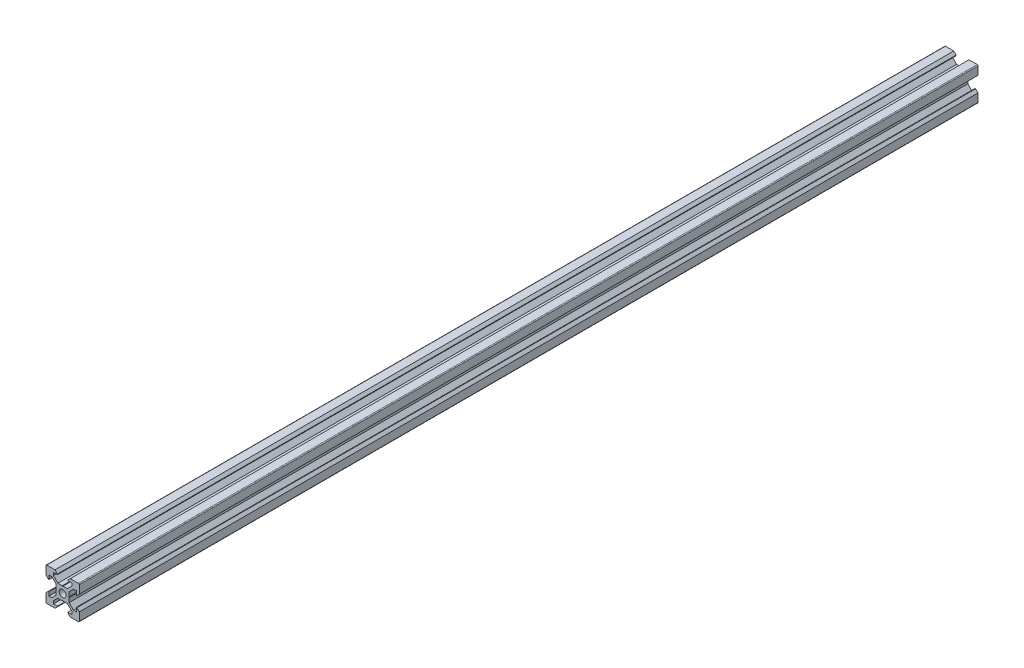
from build123d import *

# Parameters (mm, degrees)
SKETCH1_R           = 2.1
BOSS_EXTRUDE1_DEPTH = 540


with BuildPart() as part:
    # Sketch1 → Boss-Extrude1 (new body)
    with BuildSketch(Plane.XY):
        with BuildLine():
            Line((4.58, -10), (9.5, -10))
            ThreePointArc((9.5, -10), (9.853553391, -9.853553391), (10, -9.5))
            Line((10, -9.5), (10, -4.58))
            Line((10, -4.58), (8.545, -3.125))
            Line((8.545, -3.125), (8.2, -3.125))
            Line((8.2, -3.125), (8.2, -5.5))
            Line((8.2, -5.5), (6.560660172, -5.5))
            Line((6.560660172, -5.5), (3.9, -2.839339828))
            Line((3.9, -2.839339828), (3.9, -0.21))
            Line((3.9, -0.21), (3.69, 0))
            Line((3.69, 0), (3.9, 0.21))
            Line((3.9, 0.21), (3.9, 2.839339828))
            Line((3.9, 2.839339828), (6.560660172, 5.5))
            Line((6.560660172, 5.5), (8.2, 5.5))
            Line((8.2, 5.5), (8.2, 3.125))
            Line((8.2, 3.125), (8.545, 3.125))
            Line((8.545, 3.125), (10, 4.58))
            Line((10, 4.58), (10, 9.5))
            ThreePointArc((10, 9.5), (9.853553391, 9.853553391), (9.5, 10))
            Line((9.5, 10), (4.58, 10))
            Line((4.58, 10), (3.125, 8.545))
            Line((3.125, 8.545), (3.125, 8.2))
            Line((3.125, 8.2), (5.5, 8.2))
            Line((5.5, 8.2), (5.5, 6.560660172))
            Line((5.5, 6.560660172), (2.839339828, 3.9))
            Line((2.839339828, 3.9), (0.21, 3.9))
            Line((0.21, 3.9), (0, 3.69))
            Line((0, 3.69), (-0.21, 3.9))
            Line((-0.21, 3.9), (-2.839339828, 3.9))
            Line((-2.839339828, 3.9), (-5.5, 6.560660172))
            Line((-5.5, 6.560660172), (-5.5, 8.2))
            Line((-5.5, 8.2), (-3.125, 8.2))
            Line((-3.125, 8.2), (-3.125, 8.545))
            Line((-3.125, 8.545), (-4.58, 10))
            Line((-4.58, 10), (-9.5, 10))
            ThreePointArc((-9.5, 10), (-9.853553391, 9.853553391), (-10, 9.5))
            Line((-10, 9.5), (-10, 4.58))
            Line((-10, 4.58), (-8.545, 3.125))
            Line((-8.545, 3.125), (-8.2, 3.125))
            Line((-8.2, 3.125), (-8.2, 5.5))
            Line((-8.2, 5.5), (-6.560660172, 5.5))
            Line((-6.560660172, 5.5), (-3.9, 2.839339828))
            Line((-3.9, 2.839339828), (-3.9, 0.21))
            Line((-3.9, 0.21), (-3.69, 0))
            Line((-3.69, 0), (-3.9, -0.21))
            Line((-3.9, -0.21), (-3.9, -2.839339828))
            Line((-3.9, -2.839339828), (-6.560660172, -5.5))
            Line((-6.560660172, -5.5), (-8.2, -5.5))
            Line((-8.2, -5.5), (-8.2, -3.125))
            Line((-8.2, -3.125), (-8.545, -3.125))
            Line((-8.545, -3.125), (-10, -4.58))
            Line((-10, -4.58), (-10, -9.5))
            ThreePointArc((-10, -9.5), (-9.853553391, -9.853553391), (-9.5, -10))
            Line((-9.5, -10), (-4.58, -10))
            Line((-4.58, -10), (-3.125, -8.545))
            Line((-3.125, -8.545), (-3.125, -8.2))
            Line((-3.125, -8.2), (-5.5, -8.2))
            Line((-5.5, -8.2), (-5.5, -6.560660172))
            Line((-5.5, -6.560660172), (-2.839339828, -3.9))
            Line((-2.839339828, -3.9), (-0.21, -3.9))
            Line((-0.21, -3.9), (0, -3.69))
            Line((0, -3.69), (0.21, -3.9))
            Line((0.21, -3.9), (2.839339828, -3.9))
            Line((2.839339828, -3.9), (5.5, -6.560660172))
            Line((5.5, -6.560660172), (5.5, -8.2))
            Line((5.5, -8.2), (3.125, -8.2))
            Line((3.125, -8.2), (3.125, -8.545))
            Line((3.125, -8.545), (4.58, -10))
        make_face()
        Circle(SKETCH1_R, mode=Mode.SUBTRACT)
    extrude(amount=BOSS_EXTRUDE1_DEPTH)


solid = part.part
